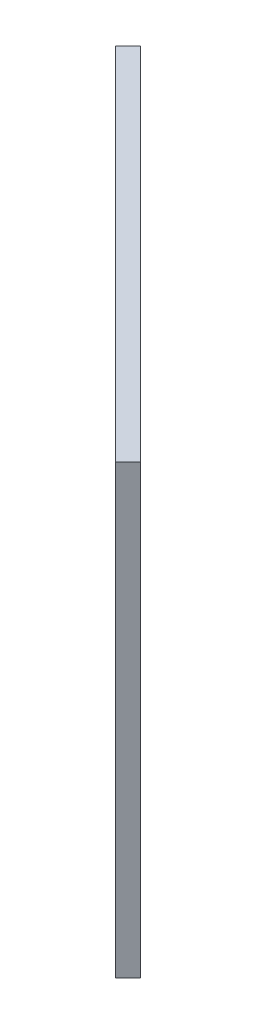
from build123d import *

# Parameters (mm, degrees)
SKETCH1_W               = 285
SKETCH1_H               = 250
BOSS_EXTRUDE1_DEPTH     = 10
CUT_EXTRUDE1_DEPTH      = 143.5
CUT_EXTRUDE1_DEPTH_BACK = 153.5
CHAMFER1_SIZE           = 2
SKETCH6_R               = 3.35
CUT_EXTRUDE4_DEPTH      = 153.5


with BuildPart() as part:
    # Sketch1 → Boss-Extrude1 (new body)
    with BuildSketch(Plane(origin=(5128.077990588, 0, -5128.077990588), x_dir=(-0.707106781, 0, -0.707106781), z_dir=(0.707106781, 0, -0.707106781))):
        with Locations((23295.770603259, 40683.217604407)):
            Rectangle(SKETCH1_W, SKETCH1_H)
    extrude(amount=BOSS_EXTRUDE1_DEPTH)

    # Sketch2 → Cut-Extrude1 (cut, two sides)
    with BuildSketch(Plane(origin=(5135.1490584, 0, -5135.1490584), x_dir=(-0.707106781, 0, -0.707106781), z_dir=(0.707106781, 0, -0.707106781))) as cut_extrude1_sk:
        with BuildLine():
            Line((23183.870603259, 40788.217604407), (23183.870603259, 40674.717604407))
            ThreePointArc((23183.870603259, 40674.717604407), (23179.870603259, 40670.717604407), (23175.870603259, 40674.717604407))
            Line((23175.870603259, 40674.717604407), (23175.870603259, 40788.217604407))
            ThreePointArc((23175.870603259, 40788.217604407), (23179.870603259, 40792.217604407), (23183.870603259, 40788.217604407))
        make_face()
        with BuildLine():
            Line((23358.670603259, 40788.217604407), (23358.670603259, 40674.717604407))
            ThreePointArc((23358.670603259, 40674.717604407), (23354.670603259, 40670.717604407), (23350.670603259, 40674.717604407))
            Line((23350.670603259, 40674.717604407), (23350.670603259, 40788.217604407))
            ThreePointArc((23350.670603259, 40788.217604407), (23354.670603259, 40792.217604407), (23358.670603259, 40788.217604407))
        make_face()
        with BuildLine():
            Line((23240.870603259, 40788.217604407), (23240.870603259, 40674.717604407))
            ThreePointArc((23240.870603259, 40674.717604407), (23236.870603259, 40670.717604407), (23232.870603259, 40674.717604407))
            Line((23232.870603259, 40674.717604407), (23232.870603259, 40788.217604407))
            ThreePointArc((23232.870603259, 40788.217604407), (23236.870603259, 40792.217604407), (23240.870603259, 40788.217604407))
        make_face()
        with BuildLine():
            Line((23415.670603259, 40788.217604407), (23415.670603259, 40674.717604407))
            ThreePointArc((23415.670603259, 40674.717604407), (23411.670603259, 40670.717604407), (23407.670603259, 40674.717604407))
            Line((23407.670603259, 40674.717604407), (23407.670603259, 40788.217604407))
            ThreePointArc((23407.670603259, 40788.217604407), (23411.670603259, 40792.217604407), (23415.670603259, 40788.217604407))
        make_face()
        with BuildLine():
            Line((23277.870603259, 40788.217604407), (23277.870603259, 40688.217604407))
            ThreePointArc((23277.870603259, 40688.217604407), (23275.770603259, 40686.117604407), (23273.670603259, 40688.217604407))
            Line((23273.670603259, 40688.217604407), (23273.670603259, 40788.217604407))
            ThreePointArc((23273.670603259, 40788.217604407), (23275.770603259, 40790.317604407), (23277.870603259, 40788.217604407))
        make_face()
        with BuildLine():
            Line((23313.670603259, 40788.217604407), (23313.670603259, 40688.217604407))
            ThreePointArc((23313.670603259, 40688.217604407), (23315.770603259, 40686.117604407), (23317.870603259, 40688.217604407))
            Line((23317.870603259, 40688.217604407), (23317.870603259, 40788.217604407))
            ThreePointArc((23317.870603259, 40788.217604407), (23315.770603259, 40790.317604407), (23313.670603259, 40788.217604407))
        make_face()
    extrude(amount=CUT_EXTRUDE1_DEPTH, mode=Mode.SUBTRACT)
    extrude(cut_extrude1_sk.sketch, amount=-CUT_EXTRUDE1_DEPTH_BACK, mode=Mode.SUBTRACT)

    # Chamfer1
    chamfer1_edges = [part.edges().sort_by_distance(p)[0] for p in [
        (-11323.306172507, 40790.317604407, -21593.604289307),
        (-11324.791096747, 40738.217604407, -21595.089213547),
        (-11323.306172507, 40686.117604407, -21593.604289307),
        (-11321.821248266, 40738.217604407, -21592.119365066),
        (-11419.40198407, 40792.217604407, -21689.70010087),
        (-11422.230411195, 40731.467604407, -21692.528527995),
        (-11419.40198407, 40670.717604407, -21689.70010087),
        (-11416.573556945, 40731.467604407, -21686.871673745),
        (-11379.096897542, 40792.217604407, -21649.395014342),
        (-11381.925324667, 40731.467604407, -21652.223441467),
        (-11379.096897542, 40670.717604407, -21649.395014342),
        (-11376.268470418, 40731.467604407, -21646.566587218),
        (-11295.799718719, 40792.217604407, -21566.097835519),
        (-11298.628145844, 40731.467604407, -21568.926262643),
        (-11295.799718719, 40670.717604407, -21566.097835519),
        (-11292.971291594, 40731.467604407, -21563.269408394),
        (-11351.590443754, 40790.317604407, -21621.888560554),
        (-11353.075367995, 40738.217604407, -21623.373484795),
        (-11351.590443754, 40686.117604407, -21621.888560554),
        (-11350.105519514, 40738.217604407, -21620.403636314),
        (-11255.494632191, 40792.217604407, -21525.792748991),
        (-11258.323059316, 40731.467604407, -21528.621176116),
        (-11255.494632191, 40670.717604407, -21525.792748991),
        (-11252.666205067, 40731.467604407, -21522.964321866),
    ]]
    chamfer(chamfer1_edges, length=CHAMFER1_SIZE)

    # Sketch6 → Cut-Extrude4 (cut, through all)
    with BuildSketch(Plane(origin=(5135.1490584, 0, -5135.1490584), x_dir=(-0.707106781, 0, -0.707106781), z_dir=(0.707106781, 0, -0.707106781))):
        with Locations((23320.047276205, 40623.466763723)):
            Circle(SKETCH6_R)
        with Locations((23280.047276205, 40623.466763723)):
            Circle(SKETCH6_R)
    extrude(amount=-CUT_EXTRUDE4_DEPTH, mode=Mode.SUBTRACT)


solid = part.part
